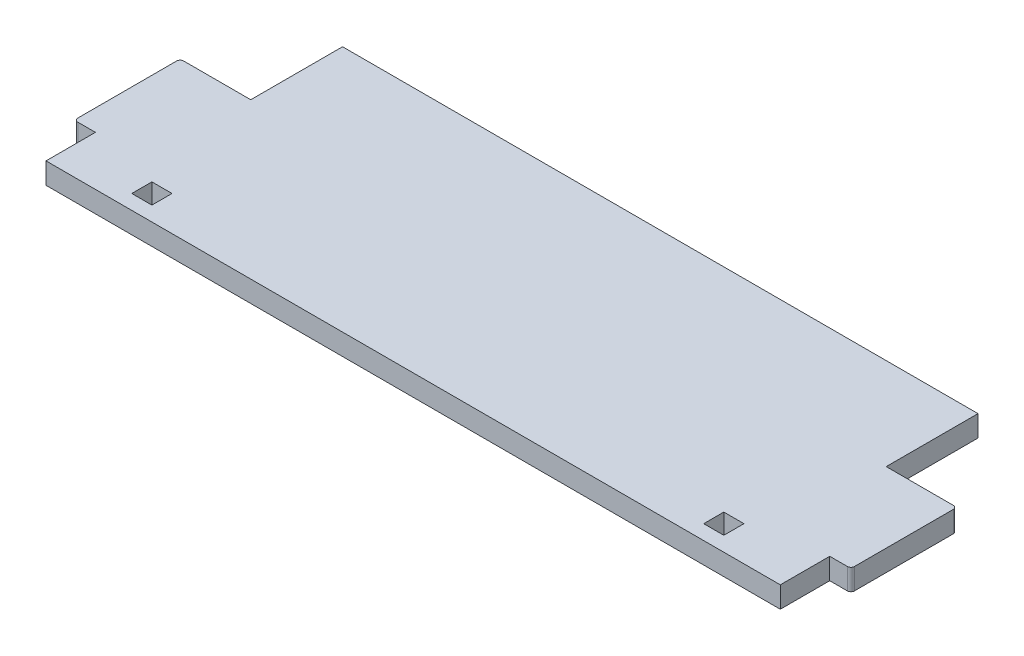
from build123d import *

# Parameters (mm, degrees)
SKETCH_1_W      = 2.85
SKETCH_1_H      = 2.85
EXTRUDE_1_DEPTH = 3
FILLET_1_R      = 0.5


with BuildPart() as part:
    # Эскиз1 → Бобышка-Вытянуть1 (new body)
    with BuildSketch(Plane(origin=(0, 0, 0), x_dir=(1, 0, 0), z_dir=(0, 1, 0))):
        Polygon((-52, 0), (52, 0), (52, 7), (55, 7), (55, 22), (45, 22), (45, 35), (-45, 35), (-45, 22), (-55, 22), (-55, 7), (-52, 7), align=None)
        with Locations((40.5, 3.5)):
            Rectangle(SKETCH_1_W, SKETCH_1_H, mode=Mode.SUBTRACT)
        with Locations((-40.5, 3.5)):
            Rectangle(SKETCH_1_W, SKETCH_1_H, mode=Mode.SUBTRACT)
    extrude(amount=EXTRUDE_1_DEPTH)

    # Скругление1
    fillet_1_edges = [part.edges().sort_by_distance(p)[0] for p in [
        (-55, 1.5, -7),
        (-55, 1.5, -22),
        (55, 1.5, -22),
        (55, 1.5, -7),
    ]]
    fillet(fillet_1_edges, radius=FILLET_1_R)


solid = part.part
